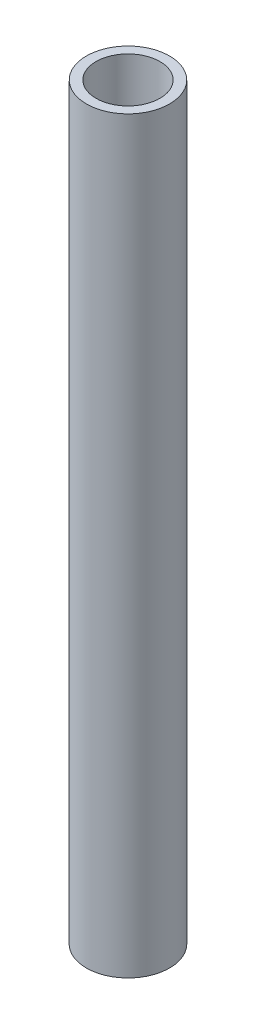
from build123d import *

# Parameters (mm, degrees)
SKETCH1_R           = 6.35
SKETCH1_R_2         = 4.8768
BOSS_EXTRUDE1_DEPTH = 114.3


with BuildPart() as part:
    # Sketch1 → Boss-Extrude1 (new body)
    with BuildSketch(Plane(origin=(0, 0, 0), x_dir=(1, 0, 0), z_dir=(0, 1, 0))):
        Circle(SKETCH1_R)
        Circle(SKETCH1_R_2, mode=Mode.SUBTRACT)
    extrude(amount=BOSS_EXTRUDE1_DEPTH)


solid = part.part
